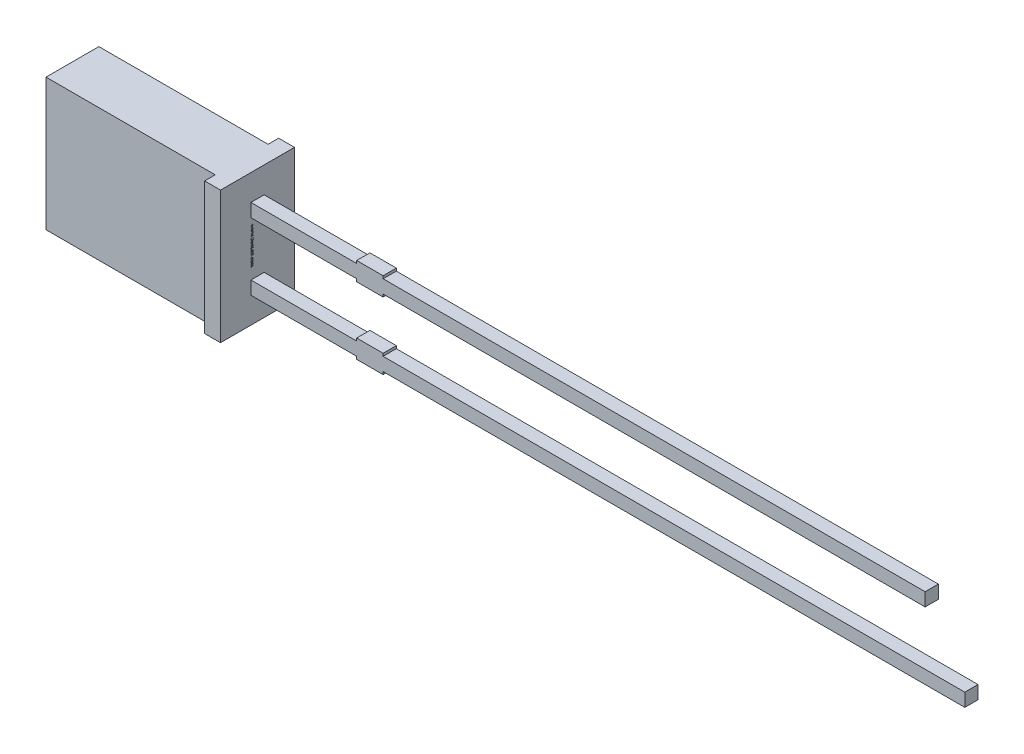
from build123d import *

# Parameters (mm, degrees)
SKETCH1_W          = 4
SKETCH1_H          = 0.5
SKETCH1_W_2        = 1
SKETCH1_W_3        = 20.5
SKETCH1_H_2        = 0.1
SKETCH1_W_4        = 22
EXTRUDE2_DEPTH     = 0.25
EXTRUDE3_DEPTH     = 1.4
EXTRUDE4_DEPTH     = 1.4
SKETCH1_7_W        = 6.4
SKETCH1_7_H        = 5
EXTRUDE5_DEPTH     = 1
SKETCH1_8_W        = 6.4
SKETCH1_8_H        = 5
EXTRUDE6_DEPTH     = 1
SKETCH2_W          = 0.026582278
SKETCH2_H          = 0.025316456
SKETCH2_H_2        = 0.025316455
CUT_EXTRUDE1_DEPTH = 0.01


with BuildPart() as part:
    # Sketch1 → Extrude2 (new body, symmetric)
    with BuildSketch(Plane.XY):
        with Locations((5.5, 1.27)):
            Rectangle(SKETCH1_W, SKETCH1_H)
        with Locations((8, 1.27)):
            Rectangle(SKETCH1_W_2, SKETCH1_H)
        with Locations((18.75, 1.27)):
            Rectangle(SKETCH1_W_3, SKETCH1_H)
        with Locations((8, 1.57)):
            Rectangle(SKETCH1_W_2, SKETCH1_H_2)
        with Locations((8, 0.97)):
            Rectangle(SKETCH1_W_2, SKETCH1_H_2)
        with Locations((8, -1.27)):
            Rectangle(SKETCH1_W_2, SKETCH1_H)
        with Locations((8, -0.97)):
            Rectangle(SKETCH1_W_2, SKETCH1_H_2)
        with Locations((19.5, -1.27)):
            Rectangle(SKETCH1_W_4, SKETCH1_H)
        with Locations((5.5, -1.27)):
            Rectangle(SKETCH1_W, SKETCH1_H)
        with Locations((8, -1.57)):
            Rectangle(SKETCH1_W_2, SKETCH1_H_2)
    extrude(amount=EXTRUDE2_DEPTH, both=True)

    # Sketch1_5 → Extrude3 (add)
    with BuildSketch(Plane.XY):
        Polygon((2.9, 2.5), (2.9, -2.5), (3.5, -2.5), (3.5, -1.52), (3.5, -1.02), (3.5, 1.02), (3.5, 1.52), (3.5, 2.5), align=None)
    extrude(amount=EXTRUDE3_DEPTH)

    # Sketch1_6 → Extrude4 (add)
    with BuildSketch(Plane.XY):
        Polygon((2.9, 2.5), (2.9, -2.5), (3.5, -2.5), (3.5, -1.52), (3.5, -1.02), (3.5, 1.02), (3.5, 1.52), (3.5, 2.5), align=None)
    extrude(amount=-EXTRUDE4_DEPTH)

    # Sketch1_7 → Extrude5 (add)
    with BuildSketch(Plane.XY):
        with Locations((-0.3, 0)):
            Rectangle(SKETCH1_7_W, SKETCH1_7_H)
    extrude(amount=EXTRUDE5_DEPTH)

    # Sketch1_8 → Extrude6 (add)
    with BuildSketch(Plane.XY):
        with Locations((-0.3, 0)):
            Rectangle(SKETCH1_8_W, SKETCH1_8_H)
    extrude(amount=-EXTRUDE6_DEPTH)

    # Sketch2 → Cut-Extrude1 (cut)
    with BuildSketch(Plane(origin=(3.5, 0, 0), x_dir=(0, 0, -1), z_dir=(1, 0, 0))):
        Polygon((-0.175316456, 0.655000082), (-0.25, 0.67845736), (-0.25, 0.70320024), (-0.199663766, 0.719616379), (-0.25, 0.735142487), (-0.25, 0.760874291), (-0.175316456, 0.784114006), (-0.175316456, 0.758936), (-0.226799842, 0.745941537), (-0.175316456, 0.729525398), (-0.175316456, 0.708026189), (-0.226799842, 0.691708943), (-0.175316456, 0.678892487), align=None)
        Polygon((-0.175316456, 0.520822867), (-0.25, 0.544280145), (-0.25, 0.569023025), (-0.199663766, 0.585439164), (-0.25, 0.600965272), (-0.25, 0.626697075), (-0.175316456, 0.649936791), (-0.175316456, 0.624758784), (-0.226799842, 0.611764322), (-0.175316456, 0.595348183), (-0.175316456, 0.573848974), (-0.226799842, 0.557531727), (-0.175316456, 0.544715272), align=None)
        Polygon((-0.175316456, 0.386645651), (-0.25, 0.41010293), (-0.25, 0.43484581), (-0.199663766, 0.451261949), (-0.25, 0.466788056), (-0.25, 0.49251986), (-0.175316456, 0.515759575), (-0.175316456, 0.490581569), (-0.226799842, 0.477587107), (-0.175316456, 0.461170968), (-0.175316456, 0.439671759), (-0.226799842, 0.423354512), (-0.175316456, 0.410538056), align=None)
        with Locations((-0.236708861, 0.35879755)):
            Rectangle(SKETCH2_W, SKETCH2_H)
        with BuildLine():
            add(Edge.make_bspline(
                [(-0.218829114, 0.242341854), (-0.220051248, 0.242378352), (-0.22245111, 0.242450023), (-0.225958798, 0.243059609), (-0.229283102, 0.244053576), (-0.232447248, 0.245425915), (-0.235416736, 0.247219372), (-0.238219628, 0.249402643), (-0.240824172, 0.251991526), (-0.243260547, 0.25493833), (-0.245442658, 0.258235272), (-0.247348691, 0.261832987), (-0.248943362, 0.265713013), (-0.250282428, 0.269861225), (-0.251270861, 0.274307771), (-0.251994849, 0.27902527), (-0.252468166, 0.284018697), (-0.252510134, 0.287442274), (-0.252531646, 0.289197075)],
                knots=[0, 0, 0, 0, 0.907312236, 1.78165839, 2.635367075, 3.479697475, 4.336364812, 5.205276731, 6.11257575, 7.058770404, 8.040786331, 9.044147278, 10.078219212, 11.153049307, 12.278104542, 13.457648573, 14.696882856, 16, 16, 16, 16], degree=3))
            add(Edge.make_bspline(
                [(-0.252531646, 0.289197075), (-0.252507574, 0.291215331), (-0.252460949, 0.295124513), (-0.25203235, 0.300788038), (-0.251386211, 0.306056075), (-0.250419669, 0.31095179), (-0.249218904, 0.31555639), (-0.247927612, 0.319989657), (-0.246463197, 0.324270969), (-0.245363039, 0.327044059), (-0.244818038, 0.328417803)],
                knots=[0, 0, 0, 0, 1.203215828, 2.33052265, 3.384689099, 4.366106119, 5.303329643, 6.221311756, 7.118865988, 8, 8, 8, 8], degree=3))
            Line((-0.244818038, 0.328417803), (-0.220886076, 0.328417803))
            Line((-0.220886076, 0.328417803), (-0.220886076, 0.325569702))
            add(Edge.make_bspline(
                [(-0.220886076, 0.325569702), (-0.221967531, 0.324204388), (-0.224124092, 0.321481775), (-0.226886697, 0.317048542), (-0.22928886, 0.312400896), (-0.231262862, 0.307555426), (-0.232849186, 0.302658581), (-0.233942713, 0.297783204), (-0.234690062, 0.293017616), (-0.234770569, 0.289859047), (-0.234810127, 0.288307044)],
                knots=[0, 0, 0, 0, 1.030622468, 2.055194264, 3.087043286, 4.125157485, 5.149848264, 6.130935704, 7.081611712, 8, 8, 8, 8], degree=3))
            add(Edge.make_bspline(
                [(-0.234810127, 0.288307044), (-0.234809232, 0.287878265), (-0.234807317, 0.286960283), (-0.234678474, 0.285492246), (-0.234585311, 0.283833647), (-0.234376093, 0.282054781), (-0.23415751, 0.280263964), (-0.23377719, 0.278609304), (-0.233415351, 0.277105665), (-0.233047173, 0.276199183), (-0.232871835, 0.275767487)],
                knots=[0, 0, 0, 0, 0.806378557, 1.726393851, 2.771014456, 3.931269413, 5.096090628, 6.161710732, 7.124547685, 8, 8, 8, 8], degree=3))
            add(Edge.make_bspline(
                [(-0.232871835, 0.275767487), (-0.232644012, 0.2752877), (-0.23219629, 0.274344817), (-0.231378683, 0.273049898), (-0.230507381, 0.271867225), (-0.229541962, 0.270805765), (-0.228364053, 0.269955497), (-0.226963197, 0.269327296), (-0.225312897, 0.268984202), (-0.224137886, 0.268944909), (-0.223516614, 0.268924132)],
                knots=[0, 0, 0, 0, 1.024407818, 2.013179384, 2.949802342, 3.859052226, 4.77034807, 5.732977883, 6.801339628, 8, 8, 8, 8], degree=3))
            add(Edge.make_bspline(
                [(-0.223516614, 0.268924132), (-0.222970718, 0.268955574), (-0.221897325, 0.269017398), (-0.220369329, 0.269599189), (-0.218947452, 0.270482088), (-0.217686737, 0.27176911), (-0.216529299, 0.273363186), (-0.215559002, 0.275318923), (-0.214678928, 0.277571902), (-0.214261659, 0.279216362), (-0.214042722, 0.280079196)],
                knots=[0, 0, 0, 0, 0.825212765, 1.622611382, 2.449701629, 3.348069183, 4.336544339, 5.428209675, 6.6506027, 8, 8, 8, 8], degree=3))
            add(Edge.make_bspline(
                [(-0.214042722, 0.280079196), (-0.213594981, 0.282047923), (-0.212677791, 0.286080831), (-0.211530684, 0.29222894), (-0.210264611, 0.298359167), (-0.20905507, 0.302317879), (-0.20846519, 0.3042485)],
                knots=[0, 0, 0, 0, 0.976104583, 1.999535498, 3.024395274, 4, 4, 4, 4], degree=3))
            add(Edge.make_bspline(
                [(-0.20846519, 0.3042485), (-0.208112197, 0.305287015), (-0.207425064, 0.307308584), (-0.206263439, 0.310200128), (-0.204993487, 0.31286124), (-0.203638356, 0.315301351), (-0.202164358, 0.317500673), (-0.200630968, 0.319495863), (-0.198977131, 0.321239388), (-0.197245211, 0.322787072), (-0.195393209, 0.324110387), (-0.193449072, 0.325265137), (-0.191388607, 0.326240772), (-0.189227318, 0.327049656), (-0.18694845, 0.327666728), (-0.184571576, 0.328087984), (-0.182088216, 0.328386373), (-0.180393863, 0.328407184), (-0.179529272, 0.328417803)],
                knots=[0, 0, 0, 0, 1.287286806, 2.505824366, 3.654938963, 4.74627059, 5.778586806, 6.75996495, 7.696030012, 8.595059759, 9.482019644, 10.363222407, 11.245851011, 12.154256429, 13.068444161, 14.012503255, 14.985824751, 16, 16, 16, 16], degree=3))
            add(Edge.make_bspline(
                [(-0.179529272, 0.328417803), (-0.178373127, 0.328380501), (-0.176097855, 0.328307092), (-0.172768811, 0.327705663), (-0.169620074, 0.326679073), (-0.166616611, 0.32529301), (-0.163803525, 0.323464382), (-0.161124978, 0.321279587), (-0.158653386, 0.31865554), (-0.156353053, 0.315678419), (-0.154273654, 0.312391034), (-0.152443098, 0.308852051), (-0.150906446, 0.305082762), (-0.149632552, 0.301097215), (-0.148677881, 0.296878746), (-0.14795895, 0.292441513), (-0.147545768, 0.287767724), (-0.147494518, 0.284576303), (-0.147468354, 0.282947075)],
                knots=[0, 0, 0, 0, 0.894990994, 1.761326291, 2.609044902, 3.454222546, 4.315366365, 5.200560057, 6.125081389, 7.100429509, 8.110379559, 9.133447974, 10.182136699, 11.259192205, 12.370181258, 13.528580438, 14.738335141, 16, 16, 16, 16], degree=3))
            add(Edge.make_bspline(
                [(-0.147468354, 0.282947075), (-0.147490546, 0.281278388), (-0.147534891, 0.277943843), (-0.147912869, 0.272962401), (-0.148468097, 0.268001899), (-0.149309803, 0.263138069), (-0.15028622, 0.258447514), (-0.151382015, 0.254034278), (-0.15261998, 0.249954818), (-0.153574325, 0.247381153), (-0.15403481, 0.246139322)],
                knots=[0, 0, 0, 0, 1.065403572, 2.129000689, 3.188532477, 4.251604565, 5.279552602, 6.247508681, 7.154397237, 8, 8, 8, 8], degree=3))
            Line((-0.15403481, 0.246139322), (-0.176582278, 0.246139322))
            Line((-0.176582278, 0.246139322), (-0.176582278, 0.248967645))
            add(Edge.make_bspline(
                [(-0.176582278, 0.248967645), (-0.175781932, 0.25004055), (-0.174145202, 0.252234668), (-0.17206153, 0.255894305), (-0.170103664, 0.259852541), (-0.168419505, 0.264131371), (-0.166960024, 0.268590399), (-0.165940858, 0.273173357), (-0.165299048, 0.277799521), (-0.165226273, 0.280901232), (-0.165189873, 0.282452613)],
                knots=[0, 0, 0, 0, 0.892283326, 1.824742884, 2.804416662, 3.836872171, 4.8899239, 5.931447339, 6.965372909, 8, 8, 8, 8], degree=3))
            add(Edge.make_bspline(
                [(-0.165189873, 0.282452613), (-0.165211326, 0.283548281), (-0.165254228, 0.285739498), (-0.165644912, 0.289007706), (-0.166275806, 0.292249767), (-0.167095088, 0.29429029), (-0.167503956, 0.295308626)],
                knots=[0, 0, 0, 0, 0.999146175, 1.998183711, 3.000980573, 4, 4, 4, 4], degree=3))
            add(Edge.make_bspline(
                [(-0.167503956, 0.295308626), (-0.167705423, 0.295742129), (-0.168108222, 0.296608847), (-0.168880786, 0.297815492), (-0.169809597, 0.29892016), (-0.170861589, 0.299912238), (-0.172017962, 0.300780635), (-0.173292788, 0.301395986), (-0.174655703, 0.301771859), (-0.175590934, 0.301814018), (-0.176068038, 0.301835525)],
                knots=[0, 0, 0, 0, 1.00524851, 2.009826503, 3.004679593, 4.035271301, 5.048246368, 6.034938417, 6.997532266, 8, 8, 8, 8], degree=3))
            add(Edge.make_bspline(
                [(-0.176068038, 0.301835525), (-0.176706203, 0.301801087), (-0.177925679, 0.301735278), (-0.179641475, 0.301128694), (-0.181119909, 0.300143861), (-0.182114829, 0.298983256), (-0.182812267, 0.297866126), (-0.183322777, 0.296830467), (-0.183806136, 0.29562124), (-0.184303605, 0.294249992), (-0.184794792, 0.292713665), (-0.185270339, 0.291005108), (-0.185719635, 0.289122391), (-0.186005825, 0.287806516), (-0.186155063, 0.287120335)],
                knots=[0, 0, 0, 0, 1.173816843, 2.243057204, 3.312297565, 4.415174738, 5.03266065, 5.73970059, 6.541434878, 7.433956553, 8.430083051, 9.515931566, 10.70464786, 12, 12, 12, 12], degree=3))
            add(Edge.make_bspline(
                [(-0.186155063, 0.287120335), (-0.186531125, 0.285287546), (-0.187270003, 0.28168652), (-0.188373491, 0.276285336), (-0.18964846, 0.270782563), (-0.190797263, 0.267117236), (-0.191396361, 0.265205778)],
                knots=[0, 0, 0, 0, 0.995744513, 1.956417928, 2.934277412, 4, 4, 4, 4], degree=3))
            add(Edge.make_bspline(
                [(-0.191396361, 0.265205778), (-0.191715605, 0.264259224), (-0.192340097, 0.262407611), (-0.19342638, 0.25976698), (-0.194600363, 0.257319921), (-0.195841894, 0.255052889), (-0.19718586, 0.252978919), (-0.198608507, 0.251084236), (-0.200135416, 0.249400418), (-0.201748644, 0.247902853), (-0.203458744, 0.246583693), (-0.205297817, 0.245451395), (-0.207246619, 0.244479167), (-0.209332819, 0.243709562), (-0.211527406, 0.243091541), (-0.213858774, 0.242668444), (-0.21630315, 0.242374461), (-0.217977728, 0.242352844), (-0.218829114, 0.242341854)],
                knots=[0, 0, 0, 0, 1.237467875, 2.420686895, 3.535046182, 4.599015201, 5.620884487, 6.594603852, 7.531477383, 8.433220087, 9.318759595, 10.202828513, 11.105163009, 12.01247538, 12.953896178, 13.926381251, 14.945733412, 16, 16, 16, 16], degree=3))
        make_face()
        with BuildLine():
            Line((-0.25, 0.149936791), (-0.25, 0.173987424))
            Line((-0.25, 0.173987424), (-0.242167722, 0.173987424))
            add(Edge.make_bspline(
                [(-0.242167722, 0.173987424), (-0.24297628, 0.175080732), (-0.244535168, 0.177188616), (-0.246615386, 0.180361641), (-0.248390652, 0.183387731), (-0.249949873, 0.186301222), (-0.251125258, 0.189323425), (-0.251953324, 0.192554939), (-0.252453097, 0.196057764), (-0.252504881, 0.198484658), (-0.252531646, 0.199739006)],
                knots=[0, 0, 0, 0, 1.150872466, 2.218865267, 3.209461834, 4.120482262, 5.012764827, 5.946708227, 6.938749913, 8, 8, 8, 8], degree=3))
            add(Edge.make_bspline(
                [(-0.252531646, 0.199739006), (-0.252508927, 0.200755358), (-0.252464686, 0.202734488), (-0.252119808, 0.205611728), (-0.251582157, 0.208319356), (-0.250774566, 0.210834396), (-0.249808763, 0.213198385), (-0.248528805, 0.215335935), (-0.247098631, 0.217339537), (-0.245391585, 0.219121209), (-0.243493852, 0.220736831), (-0.241361392, 0.222119381), (-0.239028466, 0.223297092), (-0.236476612, 0.22423819), (-0.233718309, 0.224993279), (-0.230739061, 0.225517211), (-0.227551934, 0.225837804), (-0.225356803, 0.225869743), (-0.224228639, 0.225886158)],
                knots=[0, 0, 0, 0, 1.109008058, 2.159558935, 3.158726032, 4.116861086, 5.039058877, 5.938775559, 6.82970133, 7.720510853, 8.624361809, 9.544451588, 10.487360536, 11.471068125, 12.508000841, 13.604731202, 14.768976642, 16, 16, 16, 16], degree=3))
            Line((-0.224228639, 0.225886158), (-0.175316456, 0.225886158))
            Line((-0.175316456, 0.225886158), (-0.175316456, 0.201835525))
            Line((-0.175316456, 0.201835525), (-0.21289557, 0.201835525))
            add(Edge.make_bspline(
                [(-0.21289557, 0.201835525), (-0.213812041, 0.201833889), (-0.215566256, 0.201830759), (-0.218072063, 0.20174842), (-0.220340235, 0.201627519), (-0.222382264, 0.201488815), (-0.224229015, 0.201235798), (-0.225895176, 0.200858089), (-0.227414778, 0.200387263), (-0.228321479, 0.199922944), (-0.228757911, 0.199699449)],
                knots=[0, 0, 0, 0, 1.361401701, 2.605856924, 3.723918663, 4.735739235, 5.645738665, 6.489217889, 7.27279937, 8, 8, 8, 8], degree=3))
            add(Edge.make_bspline(
                [(-0.228757911, 0.199699449), (-0.229156626, 0.199469442), (-0.229940466, 0.199017269), (-0.230946644, 0.198096979), (-0.231790911, 0.197018236), (-0.23244694, 0.195740633), (-0.232945889, 0.194254084), (-0.233286125, 0.192526154), (-0.233501627, 0.190540792), (-0.233529535, 0.189131774), (-0.233544304, 0.188386158)],
                knots=[0, 0, 0, 0, 0.849138082, 1.669332372, 2.503455908, 3.370611167, 4.311442699, 5.394692208, 6.621337967, 8, 8, 8, 8], degree=3))
            add(Edge.make_bspline(
                [(-0.233544304, 0.188386158), (-0.233526947, 0.187844874), (-0.233491259, 0.186731957), (-0.233258814, 0.185020644), (-0.232902139, 0.183224067), (-0.232242283, 0.180709484), (-0.231056104, 0.177542857), (-0.229701697, 0.175183555), (-0.229015032, 0.173987424)],
                knots=[0, 0, 0, 0, 0.638127216, 1.312033637, 2.033062677, 2.79661882, 4.375931797, 6, 6, 6, 6], degree=3))
            Line((-0.229015032, 0.173987424), (-0.175316456, 0.173987424))
            Line((-0.175316456, 0.173987424), (-0.175316456, 0.149936791))
            Line((-0.175316456, 0.149936791), (-0.25, 0.149936791))
        make_face()
        with BuildLine():
            Line((-0.25, 0.052468436), (-0.25, 0.076519069))
            Line((-0.25, 0.076519069), (-0.212420886, 0.076519069))
            add(Edge.make_bspline(
                [(-0.212420886, 0.076519069), (-0.210890843, 0.076543584), (-0.207839818, 0.076592467), (-0.204077407, 0.076874591), (-0.201235083, 0.077253113), (-0.199397202, 0.077622768), (-0.197849063, 0.078054468), (-0.196963303, 0.078466748), (-0.196558544, 0.078655145)],
                knots=[0, 0, 0, 0, 1.709124929, 3.408128882, 4.211124727, 4.91016634, 5.501986363, 6, 6, 6, 6], degree=3))
            add(Edge.make_bspline(
                [(-0.196558544, 0.078655145), (-0.196160491, 0.078899608), (-0.195380051, 0.079378911), (-0.194367038, 0.080316235), (-0.193538197, 0.081410122), (-0.192856647, 0.082680891), (-0.192386066, 0.084172088), (-0.191992836, 0.085888828), (-0.191825927, 0.087875446), (-0.191790767, 0.089282716), (-0.191772152, 0.090027772)],
                knots=[0, 0, 0, 0, 0.86006424, 1.686277094, 2.52783008, 3.38194165, 4.331801563, 5.402842185, 6.624978739, 8, 8, 8, 8], degree=3))
            add(Edge.make_bspline(
                [(-0.191772152, 0.090027772), (-0.191828889, 0.091159593), (-0.191944743, 0.093470688), (-0.19265625, 0.096332881), (-0.193475209, 0.098663485), (-0.19423404, 0.10051601), (-0.195205482, 0.10242464), (-0.195927304, 0.103704052), (-0.196301424, 0.10436717)],
                knots=[0, 0, 0, 0, 1.338371478, 2.732853438, 3.468019217, 4.261884641, 5.099136535, 6, 6, 6, 6], degree=3))
            Line((-0.196301424, 0.10436717), (-0.25, 0.10436717))
            Line((-0.25, 0.10436717), (-0.25, 0.128417803))
            Line((-0.25, 0.128417803), (-0.175316456, 0.128417803))
            Line((-0.175316456, 0.128417803), (-0.175316456, 0.10436717))
            Line((-0.175316456, 0.10436717), (-0.183148734, 0.10436717))
            add(Edge.make_bspline(
                [(-0.183148734, 0.10436717), (-0.182342583, 0.103309764), (-0.18077336, 0.101251459), (-0.17873294, 0.098072221), (-0.176934171, 0.094988323), (-0.175421354, 0.091935314), (-0.174214579, 0.088820359), (-0.17340359, 0.0855576), (-0.172859787, 0.082141194), (-0.172810094, 0.079804479), (-0.17278481, 0.078615588)],
                knots=[0, 0, 0, 0, 1.126119141, 2.192057864, 3.198061997, 4.149848529, 5.076251285, 6.021887753, 6.99356175, 8, 8, 8, 8], degree=3))
            add(Edge.make_bspline(
                [(-0.17278481, 0.078615588), (-0.172810199, 0.077619317), (-0.172859763, 0.075674418), (-0.173169473, 0.072839657), (-0.173720137, 0.070168236), (-0.174517966, 0.067675962), (-0.175503578, 0.065333343), (-0.176735093, 0.063171398), (-0.178193516, 0.061179327), (-0.179854519, 0.059350926), (-0.181744245, 0.057720108), (-0.18386151, 0.056303072), (-0.186204606, 0.055123091), (-0.188764915, 0.054152378), (-0.191530024, 0.053377955), (-0.19452599, 0.052862824), (-0.197730169, 0.05250904), (-0.199946212, 0.052482242), (-0.201087816, 0.052468436)],
                knots=[0, 0, 0, 0, 1.08848837, 2.124922927, 3.110950502, 4.063144162, 4.979605775, 5.882838355, 6.774625441, 7.671951181, 8.57587277, 9.494821853, 10.448322275, 11.435533005, 12.482327682, 13.580118324, 14.753386918, 16, 16, 16, 16], degree=3))
            Line((-0.201087816, 0.052468436), (-0.25, 0.052468436))
        make_face()
        Polygon((-0.25, -0.042468273), (-0.25, 0.029683626), (-0.15, 0.029683626), (-0.15, 0.00436717), (-0.231012658, 0.00436717), (-0.231012658, -0.042468273), align=None)
        Polygon((-0.25, -0.129810045), (-0.25, -0.057658146), (-0.15, -0.057658146), (-0.15, -0.129810045), (-0.168987342, -0.129810045), (-0.168987342, -0.082974602), (-0.186708861, -0.082974602), (-0.186708861, -0.126012576), (-0.205696203, -0.126012576), (-0.205696203, -0.082974602), (-0.231012658, -0.082974602), (-0.231012658, -0.129810045), align=None)
        with BuildLine():
            add(Edge.make_bspline(
                [(-0.200098892, -0.246265741), (-0.201246581, -0.246246426), (-0.203519467, -0.246208174), (-0.206884274, -0.245912982), (-0.210149949, -0.245386957), (-0.213334198, -0.244707776), (-0.216413126, -0.24378527), (-0.219420703, -0.242703556), (-0.222326196, -0.24139391), (-0.225127631, -0.239889058), (-0.227799734, -0.238239585), (-0.230319942, -0.236464836), (-0.23270316, -0.234619057), (-0.234898054, -0.232629744), (-0.236940074, -0.230550563), (-0.238830888, -0.228375034), (-0.240534319, -0.22606997), (-0.241557203, -0.224462807), (-0.242068829, -0.223658937)],
                knots=[0, 0, 0, 0, 1.105570398, 2.18947457, 3.250358341, 4.290584537, 5.323553275, 6.344225964, 7.367641686, 8.3905646, 9.405808457, 10.390761353, 11.358902336, 12.307789878, 13.241960776, 14.165076779, 15.082208636, 16, 16, 16, 16], degree=3))
            add(Edge.make_bspline(
                [(-0.242068829, -0.223658937), (-0.242780968, -0.222419709), (-0.244208881, -0.219934929), (-0.245877472, -0.215951095), (-0.247281588, -0.211825612), (-0.248336012, -0.207475226), (-0.249063056, -0.202828216), (-0.249623862, -0.197826807), (-0.249925622, -0.192419217), (-0.249974642, -0.188684323), (-0.25, -0.186752292)],
                knots=[0, 0, 0, 0, 0.896288622, 1.797150563, 2.705281913, 3.629615989, 4.602417572, 5.655716007, 6.787320449, 8, 8, 8, 8], degree=3))
            Line((-0.25, -0.186752292), (-0.25, -0.151329032))
            Line((-0.25, -0.151329032), (-0.15, -0.151329032))
            Line((-0.15, -0.151329032), (-0.15, -0.187760994))
            add(Edge.make_bspline(
                [(-0.15, -0.187760994), (-0.150016611, -0.189739726), (-0.150048652, -0.193556454), (-0.150466242, -0.199073293), (-0.151063066, -0.204178501), (-0.151987937, -0.208863849), (-0.153103282, -0.213163854), (-0.154462411, -0.21708933), (-0.155961118, -0.220701104), (-0.157234811, -0.222879946), (-0.157852057, -0.223935836)],
                knots=[0, 0, 0, 0, 1.267175336, 2.444223962, 3.542125549, 4.557526608, 5.500936977, 6.385043188, 7.217374394, 8, 8, 8, 8], degree=3))
            add(Edge.make_bspline(
                [(-0.157852057, -0.223935836), (-0.158388598, -0.224786789), (-0.159455511, -0.226478914), (-0.161237363, -0.228880128), (-0.16319344, -0.231109556), (-0.165245259, -0.233238059), (-0.167448146, -0.235217876), (-0.169786853, -0.237061076), (-0.172264947, -0.238764893), (-0.174874416, -0.240322856), (-0.177604468, -0.241743671), (-0.180477527, -0.242932977), (-0.183456057, -0.243982326), (-0.186565019, -0.244787862), (-0.189772856, -0.245485777), (-0.1931142, -0.245920511), (-0.196566688, -0.246207122), (-0.198911578, -0.246246037), (-0.200098892, -0.246265741)],
                knots=[0, 0, 0, 0, 0.964065863, 1.917049184, 2.86229036, 3.805247319, 4.749389377, 5.698846072, 6.657678277, 7.629829384, 8.610569287, 9.604676042, 10.607940105, 11.6349849, 12.681042988, 13.752616828, 14.862056989, 16, 16, 16, 16], degree=3))
        make_face()
        with BuildLine():
            add(Edge.make_bspline(
                [(-0.199940665, -0.219683463), (-0.199135905, -0.219673222), (-0.197557321, -0.219653134), (-0.195241806, -0.219461567), (-0.193012156, -0.219202511), (-0.190877464, -0.218771457), (-0.188817893, -0.21827181), (-0.186860399, -0.21762966), (-0.184980826, -0.216905264), (-0.183203337, -0.216023626), (-0.181494955, -0.215049989), (-0.17990944, -0.213902496), (-0.178396553, -0.212654158), (-0.176968569, -0.211275871), (-0.175662673, -0.209732931), (-0.174432597, -0.208072829), (-0.173304271, -0.20627247), (-0.172644221, -0.204999482), (-0.172310127, -0.20435514)],
                knots=[0, 0, 0, 0, 1.152093354, 2.259898929, 3.325467225, 4.364140538, 5.376172865, 6.358396836, 7.312077728, 8.257828931, 9.196960457, 10.124297759, 11.056236784, 12.004246951, 12.961658638, 13.947279359, 14.960983522, 16, 16, 16, 16], degree=3))
            add(Edge.make_bspline(
                [(-0.172310127, -0.20435514), (-0.172003415, -0.203680242), (-0.17139549, -0.202342548), (-0.170664298, -0.200271725), (-0.170091462, -0.198182341), (-0.169660604, -0.195980742), (-0.169338673, -0.193510982), (-0.169141415, -0.1905854), (-0.168999245, -0.187129491), (-0.168991494, -0.184642776), (-0.168987342, -0.183310836)],
                knots=[0, 0, 0, 0, 0.826967603, 1.639107464, 2.447640171, 3.242670507, 4.14065217, 5.225198036, 6.513753944, 8, 8, 8, 8], degree=3))
            Line((-0.168987342, -0.183310836), (-0.168987342, -0.176645488))
            Line((-0.168987342, -0.176645488), (-0.231012658, -0.176645488))
            Line((-0.231012658, -0.176645488), (-0.231012658, -0.183310836))
            add(Edge.make_bspline(
                [(-0.231012658, -0.183310836), (-0.231007909, -0.184069043), (-0.230998739, -0.185532808), (-0.230955677, -0.187649052), (-0.230908789, -0.189614848), (-0.230792327, -0.191419719), (-0.230719681, -0.193078404), (-0.230541302, -0.194565185), (-0.230399122, -0.195907674), (-0.230131399, -0.197475271), (-0.229715216, -0.199328437), (-0.229037037, -0.201489697), (-0.228186642, -0.203630231), (-0.227501675, -0.205018804), (-0.227155854, -0.205719855)],
                knots=[0, 0, 0, 0, 1.186793418, 2.291178421, 3.313283093, 4.264083014, 5.122158624, 5.910777728, 6.607099052, 7.234812932, 8.398911528, 9.577194775, 10.776795607, 12, 12, 12, 12], degree=3))
            add(Edge.make_bspline(
                [(-0.227155854, -0.205719855), (-0.226814338, -0.206304971), (-0.226140824, -0.207458896), (-0.22500675, -0.209082401), (-0.223799025, -0.210590119), (-0.222510574, -0.211986131), (-0.221122333, -0.213249431), (-0.219655791, -0.21440145), (-0.218107813, -0.215431898), (-0.215914295, -0.216667287), (-0.212883358, -0.217890533), (-0.208915972, -0.218930076), (-0.204556209, -0.219566947), (-0.201518591, -0.219643629), (-0.199940665, -0.219683463)],
                knots=[0, 0, 0, 0, 0.755160452, 1.489275589, 2.205657296, 2.907868421, 3.605098304, 4.296256403, 4.985378686, 5.676536785, 7.100390329, 8.614249252, 10.241231541, 12, 12, 12, 12], degree=3))
        make_face(mode=Mode.SUBTRACT)
        with Locations((-0.236708861, -0.277911311)):
            Rectangle(SKETCH2_W, SKETCH2_H_2)
        with BuildLine():
            add(Edge.make_bspline(
                [(-0.252531646, -0.352555298), (-0.252509834, -0.350965185), (-0.252467023, -0.347844049), (-0.251990106, -0.343272707), (-0.25127241, -0.338907534), (-0.250251504, -0.334761226), (-0.248904008, -0.330847435), (-0.247251072, -0.327183797), (-0.245265888, -0.32377694), (-0.243686679, -0.321718293), (-0.242899525, -0.320692165)],
                knots=[0, 0, 0, 0, 1.123670284, 2.205584497, 3.245308791, 4.249063313, 5.220352711, 6.167273909, 7.086481357, 8, 8, 8, 8], degree=3))
            add(Edge.make_bspline(
                [(-0.242899525, -0.320692165), (-0.242044751, -0.319740418), (-0.240338508, -0.317840603), (-0.237367081, -0.31537467), (-0.234084037, -0.313251584), (-0.230481815, -0.311466031), (-0.226565086, -0.310035108), (-0.222320424, -0.309011974), (-0.217759643, -0.308392728), (-0.21461171, -0.308325563), (-0.212994462, -0.308291057)],
                knots=[0, 0, 0, 0, 0.916457077, 1.82937027, 2.759194969, 3.714948755, 4.706655623, 5.743329475, 6.840637961, 8, 8, 8, 8], degree=3))
            add(Edge.make_bspline(
                [(-0.212994462, -0.308291057), (-0.211291235, -0.308329818), (-0.207990155, -0.308404941), (-0.203217967, -0.3090687), (-0.198800287, -0.310138313), (-0.194748378, -0.311675871), (-0.191055187, -0.313606313), (-0.187683352, -0.315870805), (-0.184640428, -0.318491331), (-0.182894988, -0.32049847), (-0.182021361, -0.321503083)],
                knots=[0, 0, 0, 0, 1.171797512, 2.271099083, 3.308930235, 4.294129479, 5.24602549, 6.17106565, 7.084581485, 8, 8, 8, 8], degree=3))
            add(Edge.make_bspline(
                [(-0.182021361, -0.321503083), (-0.181252774, -0.322528953), (-0.179706318, -0.324593085), (-0.177805619, -0.32799659), (-0.176210833, -0.331619805), (-0.174963188, -0.335449375), (-0.174009283, -0.339422184), (-0.173285439, -0.343481844), (-0.172864881, -0.347628097), (-0.172811629, -0.350418297), (-0.17278481, -0.351823494)],
                knots=[0, 0, 0, 0, 0.952130878, 1.915761808, 2.890227217, 3.891541892, 4.905612075, 5.925811839, 6.955400088, 8, 8, 8, 8], degree=3))
            add(Edge.make_bspline(
                [(-0.17278481, -0.351823494), (-0.172801812, -0.353070213), (-0.172835245, -0.355521684), (-0.173157354, -0.359122731), (-0.173690473, -0.362577272), (-0.174429076, -0.365882204), (-0.175320679, -0.36905615), (-0.17635982, -0.372106327), (-0.177493088, -0.375066138), (-0.178377623, -0.376966707), (-0.178817247, -0.377911311)],
                knots=[0, 0, 0, 0, 1.107648782, 2.178012834, 3.209595929, 4.211695017, 5.185427128, 6.137685403, 7.07440854, 8, 8, 8, 8], degree=3))
            Line((-0.178817247, -0.377911311), (-0.199367089, -0.377911311))
            Line((-0.199367089, -0.377911311), (-0.199367089, -0.374568747))
            add(Edge.make_bspline(
                [(-0.199367089, -0.374568747), (-0.198949869, -0.374069203), (-0.198048154, -0.372989567), (-0.196627402, -0.371203151), (-0.195097809, -0.36905421), (-0.194205863, -0.367400674), (-0.193730222, -0.366518906)],
                knots=[0, 0, 0, 0, 0.792826818, 1.713491785, 2.780691913, 4, 4, 4, 4], degree=3))
            add(Edge.make_bspline(
                [(-0.193730222, -0.366518906), (-0.193288264, -0.365590971), (-0.192382404, -0.363689026), (-0.19154957, -0.361133021), (-0.190981844, -0.358941019), (-0.190725422, -0.357123483), (-0.190535861, -0.355189862), (-0.190516354, -0.35385462), (-0.190506329, -0.353168431)],
                knots=[0, 0, 0, 0, 1.332524827, 2.731214173, 3.480270227, 4.267952375, 5.109889624, 6, 6, 6, 6], degree=3))
            add(Edge.make_bspline(
                [(-0.190506329, -0.353168431), (-0.190525879, -0.352402875), (-0.190563765, -0.350919265), (-0.190840821, -0.348757756), (-0.191319079, -0.346739345), (-0.191959179, -0.344836123), (-0.192846792, -0.34309806), (-0.193880429, -0.34147122), (-0.195106231, -0.33997896), (-0.196547173, -0.338659699), (-0.198127102, -0.337466973), (-0.199861217, -0.336447771), (-0.201707816, -0.335535315), (-0.203712265, -0.334840377), (-0.205841041, -0.334280639), (-0.208104161, -0.333891709), (-0.210503671, -0.33364975), (-0.212149979, -0.333621833), (-0.212994462, -0.333607513)],
                knots=[0, 0, 0, 0, 1.087302107, 2.107140881, 3.088415001, 4.030197574, 4.951552271, 5.852940509, 6.764198256, 7.685219758, 8.621679636, 9.570836121, 10.538340132, 11.542450476, 12.578202196, 13.66207107, 14.800746211, 16, 16, 16, 16], degree=3))
            add(Edge.make_bspline(
                [(-0.212994462, -0.333607513), (-0.213858618, -0.333622288), (-0.215537631, -0.333650994), (-0.217979242, -0.333884508), (-0.220260673, -0.334300399), (-0.222385993, -0.334871647), (-0.224352011, -0.335595995), (-0.226149408, -0.336501112), (-0.227806215, -0.337537469), (-0.229268827, -0.338782027), (-0.230585149, -0.34014591), (-0.231721283, -0.341660802), (-0.232669428, -0.343320041), (-0.233473891, -0.345102222), (-0.234052289, -0.347035262), (-0.234488981, -0.349091799), (-0.234777538, -0.351281354), (-0.234799101, -0.352791708), (-0.234810127, -0.353564)],
                knots=[0, 0, 0, 0, 1.230336593, 2.390482092, 3.487897344, 4.52859895, 5.520747884, 6.465347575, 7.38981449, 8.296085817, 9.192433006, 10.084246191, 10.984321635, 11.908883871, 12.862027947, 13.850751296, 14.901019963, 16, 16, 16, 16], degree=3))
            add(Edge.make_bspline(
                [(-0.234810127, -0.353564), (-0.234801999, -0.354289855), (-0.234786155, -0.35570488), (-0.234568078, -0.357769626), (-0.234292195, -0.359730535), (-0.233852787, -0.361566075), (-0.233310412, -0.363261341), (-0.232743906, -0.364821764), (-0.232139122, -0.366234212), (-0.231671567, -0.367095566), (-0.231447785, -0.36750783)],
                knots=[0, 0, 0, 0, 1.200823684, 2.340960236, 3.433630075, 4.476504061, 5.46014544, 6.378484521, 7.223905657, 8, 8, 8, 8], degree=3))
            add(Edge.make_bspline(
                [(-0.231447785, -0.36750783), (-0.23101789, -0.368208035), (-0.230186248, -0.369562602), (-0.228784682, -0.37140133), (-0.227370422, -0.373046199), (-0.226414205, -0.37407071), (-0.225949367, -0.374568747)],
                knots=[0, 0, 0, 0, 1.098601379, 2.125273733, 3.088655601, 4, 4, 4, 4], degree=3))
            Line((-0.225949367, -0.374568747), (-0.225949367, -0.377911311))
            Line((-0.225949367, -0.377911311), (-0.246657437, -0.377911311))
            add(Edge.make_bspline(
                [(-0.246657437, -0.377911311), (-0.247094931, -0.376965921), (-0.247970024, -0.375074914), (-0.249123896, -0.372160334), (-0.250092057, -0.369172362), (-0.250995137, -0.366123989), (-0.251683499, -0.362951906), (-0.252176622, -0.359628875), (-0.252477534, -0.356147377), (-0.252513362, -0.353768988), (-0.252531646, -0.352555298)],
                knots=[0, 0, 0, 0, 0.952012952, 1.904254716, 2.862729541, 3.822037426, 4.808956931, 5.82647221, 6.890850784, 8, 8, 8, 8], degree=3))
        make_face()
        with BuildLine():
            add(Edge.make_bspline(
                [(-0.212697785, -0.470316374), (-0.214202691, -0.470291678), (-0.217136157, -0.47024354), (-0.221407948, -0.469704223), (-0.225443946, -0.468891444), (-0.229231154, -0.467718912), (-0.232788429, -0.46623852), (-0.236078221, -0.464387581), (-0.239131451, -0.462216576), (-0.241921336, -0.459725539), (-0.244419846, -0.456924337), (-0.246615099, -0.453850155), (-0.248428541, -0.450476328), (-0.249940631, -0.446862017), (-0.251109866, -0.442977365), (-0.251922584, -0.438823146), (-0.252458054, -0.434406011), (-0.252506706, -0.431367593), (-0.252531646, -0.429810045)],
                knots=[0, 0, 0, 0, 1.120167703, 2.183507516, 3.201345984, 4.182878364, 5.131270247, 6.065524964, 6.98789854, 7.91635504, 8.84481154, 9.778033504, 10.722808862, 11.691211189, 12.691525459, 13.738229926, 14.840575679, 16, 16, 16, 16], degree=3))
            add(Edge.make_bspline(
                [(-0.252531646, -0.429810045), (-0.252506624, -0.428252524), (-0.252457811, -0.425214158), (-0.25192348, -0.420796648), (-0.251105529, -0.416637554), (-0.249949428, -0.412748247), (-0.248422879, -0.409139501), (-0.246615831, -0.405769634), (-0.244419638, -0.402695869), (-0.241921446, -0.399894383), (-0.239131219, -0.397404065), (-0.236079037, -0.395230474), (-0.232783083, -0.39338806), (-0.229240037, -0.391870206), (-0.225439199, -0.390736882), (-0.221408758, -0.389913419), (-0.217135938, -0.389377211), (-0.214202617, -0.389328636), (-0.212697785, -0.389303716)],
                knots=[0, 0, 0, 0, 1.15937715, 2.261678054, 3.308339936, 4.313313916, 5.277148057, 6.221884977, 7.155068972, 8.083487698, 9.011906424, 9.934242473, 10.868459181, 11.818729666, 12.798784262, 13.81658132, 14.879877871, 16, 16, 16, 16], degree=3))
            add(Edge.make_bspline(
                [(-0.212697785, -0.389303716), (-0.211186361, -0.389328839), (-0.208233351, -0.389377924), (-0.203934478, -0.389913294), (-0.199873828, -0.390731311), (-0.196065514, -0.391891343), (-0.192513914, -0.393407616), (-0.18921181, -0.395248641), (-0.186165235, -0.397445108), (-0.183375483, -0.399954607), (-0.180879102, -0.402766401), (-0.178706197, -0.405860333), (-0.176869539, -0.409212252), (-0.175347706, -0.412819451), (-0.174213141, -0.416706006), (-0.173395562, -0.420842949), (-0.17285749, -0.425240343), (-0.172809478, -0.428259081), (-0.17278481, -0.429810045)],
                knots=[0, 0, 0, 0, 1.124034801, 2.196132384, 3.217834281, 4.203147447, 5.152578239, 6.085969439, 7.010345409, 7.941219594, 8.872481455, 9.802010446, 10.748267785, 11.711250247, 12.709230373, 13.754967386, 14.846549946, 16, 16, 16, 16], degree=3))
            add(Edge.make_bspline(
                [(-0.17278481, -0.429810045), (-0.172809532, -0.431380783), (-0.172857665, -0.434438947), (-0.173393868, -0.438882358), (-0.174206873, -0.443056198), (-0.175373269, -0.446954823), (-0.176884682, -0.450580573), (-0.17871934, -0.453940648), (-0.180921398, -0.457011956), (-0.183428554, -0.45979921), (-0.186233956, -0.462279451), (-0.189283579, -0.464448367), (-0.192603295, -0.466255585), (-0.196158163, -0.467737355), (-0.199951933, -0.468909528), (-0.203986038, -0.469730513), (-0.208261035, -0.470236504), (-0.211193165, -0.470289288), (-0.212697785, -0.470316374)],
                knots=[0, 0, 0, 0, 1.167358552, 2.272800965, 3.322628764, 4.326027541, 5.29287265, 6.238482395, 7.166210353, 8.096447471, 9.020151799, 9.945039072, 10.873038967, 11.824425184, 12.804379233, 13.820580988, 14.881633558, 16, 16, 16, 16], degree=3))
        make_face()
        with BuildLine():
            add(Edge.make_bspline(
                [(-0.231190665, -0.440609095), (-0.230690658, -0.440964273), (-0.229673086, -0.441687102), (-0.227972663, -0.442557354), (-0.226150868, -0.443345359), (-0.224121587, -0.443963554), (-0.221819141, -0.444442876), (-0.219165549, -0.444754267), (-0.216130036, -0.444983911), (-0.213977323, -0.444994373), (-0.212836234, -0.444999918)],
                knots=[0, 0, 0, 0, 0.764956307, 1.556776596, 2.379454426, 3.241401993, 4.200532455, 5.312591107, 6.575484591, 8, 8, 8, 8], degree=3))
            add(Edge.make_bspline(
                [(-0.212836234, -0.444999918), (-0.211761353, -0.444982229), (-0.209701996, -0.444948339), (-0.206742233, -0.444761969), (-0.204058807, -0.444413295), (-0.201641411, -0.443915416), (-0.199470723, -0.443305646), (-0.19752836, -0.442579711), (-0.195809758, -0.441741193), (-0.194804527, -0.441055726), (-0.194323576, -0.440727766)],
                knots=[0, 0, 0, 0, 1.337076348, 2.561692668, 3.686680134, 4.69989255, 5.629188848, 6.488203485, 7.276684665, 8, 8, 8, 8], degree=3))
            add(Edge.make_bspline(
                [(-0.194323576, -0.440727766), (-0.193884293, -0.440390469), (-0.193022537, -0.439728779), (-0.191940352, -0.438552728), (-0.191042058, -0.437288169), (-0.190382017, -0.435907867), (-0.189862759, -0.4344627), (-0.189515923, -0.432954374), (-0.189287802, -0.431399222), (-0.189256424, -0.430344886), (-0.189240506, -0.429810045)],
                knots=[0, 0, 0, 0, 1.058684453, 2.076859345, 3.046867319, 4.017860406, 4.996047344, 5.981941452, 6.976284511, 8, 8, 8, 8], degree=3))
            add(Edge.make_bspline(
                [(-0.189240506, -0.429810045), (-0.189251453, -0.429282113), (-0.189272863, -0.428249496), (-0.189452545, -0.42674683), (-0.189747135, -0.425335882), (-0.190165068, -0.423996008), (-0.190760551, -0.422704034), (-0.191616975, -0.421469689), (-0.192692306, -0.420253752), (-0.193542825, -0.419515505), (-0.193987342, -0.419129665)],
                knots=[0, 0, 0, 0, 1.041978199, 2.038073998, 2.982578265, 3.884042198, 4.804014415, 5.778706634, 6.839057036, 8, 8, 8, 8], degree=3))
            add(Edge.make_bspline(
                [(-0.193987342, -0.419129665), (-0.194461968, -0.41879618), (-0.195460568, -0.418094536), (-0.197165089, -0.417211561), (-0.199127009, -0.416480207), (-0.20131075, -0.415787967), (-0.203781898, -0.415269703), (-0.206535176, -0.414868964), (-0.209589603, -0.41466825), (-0.21172182, -0.414636674), (-0.212836234, -0.414620171)],
                knots=[0, 0, 0, 0, 0.706185926, 1.485796665, 2.33004681, 3.254820698, 4.274138656, 5.402098861, 6.642194297, 8, 8, 8, 8], degree=3))
            add(Edge.make_bspline(
                [(-0.212836234, -0.414620171), (-0.213838698, -0.414629318), (-0.21577981, -0.414647028), (-0.218586195, -0.414845943), (-0.221190128, -0.415174619), (-0.22358016, -0.415651263), (-0.225765057, -0.416225507), (-0.227716716, -0.416972981), (-0.229471774, -0.417796455), (-0.230499515, -0.418496793), (-0.23099288, -0.418832988)],
                knots=[0, 0, 0, 0, 1.270915159, 2.460926195, 3.565223763, 4.596447547, 5.549594966, 6.425286377, 7.244063354, 8, 8, 8, 8], degree=3))
            add(Edge.make_bspline(
                [(-0.23099288, -0.418832988), (-0.231409366, -0.419173548), (-0.232230494, -0.419844985), (-0.233314509, -0.420993903), (-0.23417586, -0.422277615), (-0.234906348, -0.423628818), (-0.235435594, -0.425090621), (-0.235812201, -0.426642513), (-0.236027955, -0.428294247), (-0.236059682, -0.429427042), (-0.236075949, -0.43000783)],
                knots=[0, 0, 0, 0, 1.011121112, 1.993489184, 2.956264801, 3.910060304, 4.874908638, 5.87009835, 6.907993364, 8, 8, 8, 8], degree=3))
            add(Edge.make_bspline(
                [(-0.236075949, -0.43000783), (-0.236022367, -0.431008779), (-0.235915445, -0.433006142), (-0.235203793, -0.435421291), (-0.234354513, -0.437228614), (-0.233475258, -0.438467885), (-0.232435719, -0.439624076), (-0.231609742, -0.440277544), (-0.231190665, -0.440609095)],
                knots=[0, 0, 0, 0, 1.48399549, 2.96126462, 3.700919455, 4.439278468, 5.208134679, 6, 6, 6, 6], degree=3))
        make_face(mode=Mode.SUBTRACT)
        with BuildLine():
            Line((-0.196301424, -0.561455614), (-0.25, -0.561455614))
            Line((-0.25, -0.561455614), (-0.25, -0.537404981))
            Line((-0.25, -0.537404981), (-0.212143987, -0.537404981))
            add(Edge.make_bspline(
                [(-0.212143987, -0.537404981), (-0.211253953, -0.537399515), (-0.209546322, -0.537389027), (-0.207086708, -0.537356003), (-0.204838103, -0.537275732), (-0.202791904, -0.537168193), (-0.200932439, -0.536981248), (-0.199257604, -0.536669909), (-0.197752078, -0.536248412), (-0.19685113, -0.535840062), (-0.196420095, -0.535644697)],
                knots=[0, 0, 0, 0, 1.339742217, 2.570446543, 3.702449567, 4.726327994, 5.654556215, 6.512888379, 7.288529137, 8, 8, 8, 8], degree=3))
            add(Edge.make_bspline(
                [(-0.196420095, -0.535644697), (-0.196034728, -0.535434771), (-0.195270835, -0.535018647), (-0.194302974, -0.534150602), (-0.193492329, -0.533142293), (-0.192850874, -0.531962131), (-0.192352712, -0.530583448), (-0.192003366, -0.528968326), (-0.191822964, -0.527104469), (-0.191789727, -0.525782181), (-0.191772152, -0.525082988)],
                knots=[0, 0, 0, 0, 0.859345536, 1.703436662, 2.532498256, 3.390183975, 4.328249457, 5.402602062, 6.626559876, 8, 8, 8, 8], degree=3))
            add(Edge.make_bspline(
                [(-0.191772152, -0.525082988), (-0.191795714, -0.524495694), (-0.191843051, -0.523315807), (-0.19208459, -0.521557333), (-0.192586536, -0.51983812), (-0.193423174, -0.517619444), (-0.194639641, -0.51501014), (-0.19576153, -0.513037724), (-0.196301424, -0.512088526)],
                knots=[0, 0, 0, 0, 0.759443456, 1.525737455, 2.286422378, 3.068189154, 4.58910569, 6, 6, 6, 6], degree=3))
            Line((-0.196301424, -0.512088526), (-0.25, -0.512088526))
            Line((-0.25, -0.512088526), (-0.25, -0.488037893))
            Line((-0.25, -0.488037893), (-0.175316456, -0.488037893))
            Line((-0.175316456, -0.488037893), (-0.175316456, -0.512088526))
            Line((-0.175316456, -0.512088526), (-0.183148734, -0.512088526))
            add(Edge.make_bspline(
                [(-0.183148734, -0.512088526), (-0.182367252, -0.513109563), (-0.180849932, -0.515092004), (-0.178803995, -0.518105977), (-0.17704056, -0.52106146), (-0.175510003, -0.523962576), (-0.174254621, -0.526909024), (-0.173417856, -0.530003523), (-0.172885536, -0.53324627), (-0.172818794, -0.535464553), (-0.17278481, -0.536594064)],
                knots=[0, 0, 0, 0, 1.136140478, 2.205924536, 3.217129804, 4.176128364, 5.103417168, 6.04061054, 7.002313223, 8, 8, 8, 8], degree=3))
            add(Edge.make_bspline(
                [(-0.17278481, -0.536594064), (-0.172816556, -0.537797307), (-0.1728786, -0.540148962), (-0.173547861, -0.543560883), (-0.174552486, -0.546776771), (-0.176042919, -0.549732778), (-0.17787572, -0.552454922), (-0.180153427, -0.554845902), (-0.182799233, -0.556960442), (-0.184810869, -0.55805057), (-0.185838608, -0.558607513)],
                knots=[0, 0, 0, 0, 1.06605855, 2.083537511, 3.073064962, 4.046068917, 5.009676085, 5.97370914, 6.964773701, 8, 8, 8, 8], degree=3))
            add(Edge.make_bspline(
                [(-0.185838608, -0.558607513), (-0.184861648, -0.5597896), (-0.182957743, -0.562093258), (-0.180415047, -0.565646852), (-0.178160747, -0.569126009), (-0.176251034, -0.572566261), (-0.174706146, -0.575961912), (-0.173600545, -0.579341039), (-0.172917099, -0.58268982), (-0.172828397, -0.584923079), (-0.17278481, -0.586020488)],
                knots=[0, 0, 0, 0, 1.188124574, 2.315425566, 3.384037189, 4.39937427, 5.362203716, 6.270239573, 7.150007311, 8, 8, 8, 8], degree=3))
            add(Edge.make_bspline(
                [(-0.17278481, -0.586020488), (-0.172808185, -0.587003746), (-0.172853665, -0.588916905), (-0.173188962, -0.591699347), (-0.1737597, -0.594295935), (-0.174553952, -0.596718501), (-0.175577368, -0.598961742), (-0.176851198, -0.601012597), (-0.178357379, -0.602867179), (-0.180057184, -0.604560068), (-0.181991531, -0.606041398), (-0.184119192, -0.60734501), (-0.186470211, -0.608393387), (-0.188998325, -0.609298604), (-0.191735603, -0.609980393), (-0.194678201, -0.610471136), (-0.197818223, -0.610769153), (-0.199979558, -0.610804552), (-0.201087816, -0.610822703)],
                knots=[0, 0, 0, 0, 1.099321551, 2.138985818, 3.128101353, 4.067593225, 4.984602876, 5.878565082, 6.75932895, 7.650734189, 8.554641537, 9.477588118, 10.434248276, 11.427530835, 12.477080043, 13.583595796, 14.760951851, 16, 16, 16, 16], degree=3))
            Line((-0.201087816, -0.610822703), (-0.25, -0.610822703))
            Line((-0.25, -0.610822703), (-0.25, -0.58677207))
            Line((-0.25, -0.58677207), (-0.212143987, -0.58677207))
            add(Edge.make_bspline(
                [(-0.212143987, -0.58677207), (-0.211247371, -0.58676636), (-0.209526576, -0.5867554), (-0.207060222, -0.586725719), (-0.204812405, -0.586636083), (-0.202772514, -0.586555538), (-0.20092038, -0.586386917), (-0.199248731, -0.586099883), (-0.197756742, -0.585669756), (-0.196851818, -0.585277864), (-0.196420095, -0.585090899)],
                knots=[0, 0, 0, 0, 1.350843832, 2.592553583, 3.715618503, 4.739861077, 5.667890227, 6.515410335, 7.291728161, 8, 8, 8, 8], degree=3))
            add(Edge.make_bspline(
                [(-0.196420095, -0.585090899), (-0.196035088, -0.584887522), (-0.19527283, -0.584484865), (-0.194297859, -0.583635748), (-0.193487251, -0.582623927), (-0.192851921, -0.581426936), (-0.192349458, -0.580023476), (-0.192008014, -0.578387125), (-0.191820551, -0.576498191), (-0.191788988, -0.575162543), (-0.191772152, -0.574450076)],
                knots=[0, 0, 0, 0, 0.846473755, 1.675897046, 2.498822796, 3.361436039, 4.304631926, 5.39613934, 6.611038701, 8, 8, 8, 8], degree=3))
            add(Edge.make_bspline(
                [(-0.191772152, -0.574450076), (-0.191819388, -0.573449102), (-0.191914406, -0.571435585), (-0.192631155, -0.568952208), (-0.193445787, -0.566930419), (-0.19422506, -0.565230473), (-0.195194386, -0.563389287), (-0.195921526, -0.562119186), (-0.196301424, -0.561455614)],
                knots=[0, 0, 0, 0, 1.291138276, 2.597198332, 3.312242316, 4.108946311, 5.012008063, 6, 6, 6, 6], degree=3))
        make_face()
    extrude(amount=-CUT_EXTRUDE1_DEPTH, mode=Mode.SUBTRACT)


solid = part.part
